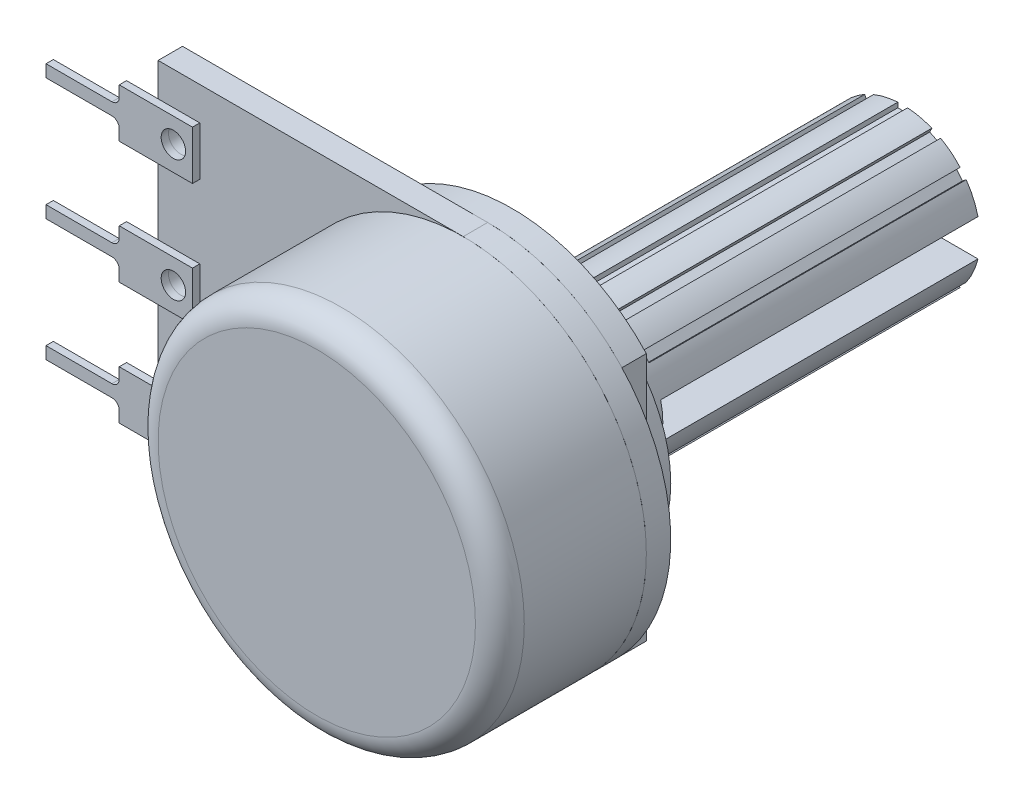
from build123d import *

# Parameters (mm, degrees)
SALIENTE_EXTRUIR1_DEPTH   = 1
CROQUIS4_R                = 7.5
SALIENTE_EXTRUIR2_DEPTH   = 6
SALIENTE_EXTRUIR3_DEPTH   = 1
CROQUIS6_R                = 5.5
SALIENTE_EXTRUIR5_DEPTH   = 1
CROQUIS7_R                = 3.175
SALIENTE_EXTRUIR6_DEPTH   = 15
CORTAR_EXTRUIR1_DEPTH     = 13
SALIENTE_EXTRUIR7_DEPTH   = 0.3
SALIENTE_EXTRUIR7_2_DEPTH = 0.3
SALIENTE_EXTRUIR7_3_DEPTH = 0.3
CROQUIS11_R               = 0.5
CORTAR_EXTRUIR2_DEPTH     = 19.3
REDONDEO1_R               = 1
REDONDEO2_R               = 1


with BuildPart() as part:
    # Croquis3 → Saliente-Extruir1 (new body)
    with BuildSketch(Plane.XY):
        with BuildLine():
            Line((12.5, 0), (0, 0))
            Line((0, 0), (0, 15))
            Line((0, 15), (12.5, 15))
            ThreePointArc((12.5, 15), (20, 7.5), (12.5, 0))
        make_face()
    extrude(amount=SALIENTE_EXTRUIR1_DEPTH)


with BuildPart() as body_2:
    # Croquis4 → Saliente-Extruir2 (new body)
    with BuildSketch(Plane.XY.offset(1)):
        with Locations((12.5, 7.5)):
            Circle(CROQUIS4_R)
    extrude(amount=SALIENTE_EXTRUIR2_DEPTH)

    # Redondeo1
    redondeo1_edges = [body_2.edges().sort_by_distance(p)[0] for p in [
        (5, 7.5, 7),
    ]]
    fillet(redondeo1_edges, radius=REDONDEO1_R)


with BuildPart() as body_3:
    # Croquis5 → Saliente-Extruir3 (new body)
    with BuildSketch(Plane(origin=(0, 0, 0), x_dir=(-1, 0, 0), z_dir=(0, 0, -1))):
        with BuildLine():
            Line((-18, 12.599019514), (-18, 2.400980486))
            ThreePointArc((-18, 2.400980486), (-12.5, 0), (-7, 2.400980486))
            Line((-7, 2.400980486), (-7, 12.599019514))
            ThreePointArc((-7, 12.599019514), (-12.5, 15), (-18, 12.599019514))
        make_face()
    extrude(amount=SALIENTE_EXTRUIR3_DEPTH)

    # Croquis6 → Saliente-Extruir5 (add)
    with BuildSketch(Plane(origin=(0, 0, -1), x_dir=(-1, 0, 0), z_dir=(0, 0, -1))):
        with Locations((-12.5, 7.5)):
            Circle(CROQUIS6_R)
    extrude(amount=SALIENTE_EXTRUIR5_DEPTH)

    # Croquis7 → Saliente-Extruir6 (add)
    with BuildSketch(Plane(origin=(0, 0, -2), x_dir=(-1, 0, 0), z_dir=(0, 0, -1))):
        with Locations((-12.5, 7.5)):
            Circle(CROQUIS7_R)
    extrude(amount=SALIENTE_EXTRUIR6_DEPTH)

    # Croquis9 → Cortar-Extruir1 (cut)
    with BuildSketch(Plane(origin=(0, 0, -17), x_dir=(-1, 0, 0), z_dir=(0, 0, -1))):
        with BuildLine():
            Line((-9.626142568, 8.25), (-15.373857432, 8.25))
            Line((-15.373857432, 8.25), (-15.438767343, 7.965611096))
            Line((-15.438767343, 7.965611096), (-15.633752926, 8.010115283))
            ThreePointArc((-15.633752926, 8.010115283), (-15.675, 7.5), (-15.633752926, 6.989884717))
            Line((-15.633752926, 6.989884717), (-15.438767343, 7.034388904))
            Line((-15.438767343, 7.034388904), (-15.373857432, 6.75))
            Line((-15.373857432, 6.75), (-9.626142568, 6.75))
            Line((-9.626142568, 6.75), (-9.561232657, 7.034388904))
            Line((-9.561232657, 7.034388904), (-9.366247074, 6.989884717))
            ThreePointArc((-9.366247074, 6.989884717), (-9.335328569, 7.244109924), (-9.325, 7.5))
            ThreePointArc((-9.325, 7.5), (-9.335328569, 7.755890076), (-9.366247074, 8.010115283))
            Line((-9.366247074, 8.010115283), (-9.561232657, 7.965611096))
            Line((-9.561232657, 7.965611096), (-9.626142568, 8.25))
        make_face()
        with BuildLine():
            Line((-14.696320882, 9.507317058), (-14.852687178, 9.632015019))
            ThreePointArc((-14.852687178, 9.632015019), (-14.982314957, 9.479580121), (-15.102083099, 9.319282426))
            Line((-15.102083099, 9.319282426), (-14.945716803, 9.194584465))
            Line((-14.945716803, 9.194584465), (-14.696320882, 9.507317058))
        make_face()
        with BuildLine():
            Line((-13.607874508, 10.261478094), (-13.694651256, 10.441671868))
            ThreePointArc((-13.694651256, 10.441671868), (-13.877580872, 10.360576156), (-14.055038803, 10.268118372))
            Line((-14.055038803, 10.268118372), (-13.968262055, 10.087924599))
            Line((-13.968262055, 10.087924599), (-13.607874508, 10.261478094))
        make_face()
        with BuildLine():
            ThreePointArc((-12.3, 10.668694526), (-12.5, 10.675), (-12.7, 10.668694526))
            Line((-12.7, 10.668694526), (-12.7, 10.468694526))
            Line((-12.7, 10.468694526), (-12.3, 10.468694526))
            Line((-12.3, 10.468694526), (-12.3, 10.668694526))
        make_face()
        with BuildLine():
            ThreePointArc((-10.944961197, 10.268118372), (-11.122419128, 10.360576156), (-11.305348744, 10.441671868))
            Line((-11.305348744, 10.441671868), (-11.392125492, 10.261478094))
            Line((-11.392125492, 10.261478094), (-11.031737945, 10.087924599))
            Line((-11.031737945, 10.087924599), (-10.944961197, 10.268118372))
        make_face()
        with BuildLine():
            ThreePointArc((-9.897916901, 9.319282426), (-10.017685043, 9.479580121), (-10.147312822, 9.632015019))
            Line((-10.147312822, 9.632015019), (-10.303679118, 9.507317058))
            Line((-10.303679118, 9.507317058), (-10.054283197, 9.194584465))
            Line((-10.054283197, 9.194584465), (-9.897916901, 9.319282426))
        make_face()
        with BuildLine():
            Line((-14.945716803, 5.805415535), (-15.102083099, 5.680717574))
            ThreePointArc((-15.102083099, 5.680717574), (-14.982314957, 5.520419879), (-14.852687178, 5.367984981))
            Line((-14.852687178, 5.367984981), (-14.696320882, 5.492682942))
            Line((-14.696320882, 5.492682942), (-14.945716803, 5.805415535))
        make_face()
        with BuildLine():
            Line((-13.968262055, 4.912075401), (-14.055038803, 4.731881628))
            ThreePointArc((-14.055038803, 4.731881628), (-13.877580872, 4.639423844), (-13.694651256, 4.558328132))
            Line((-13.694651256, 4.558328132), (-13.607874508, 4.738521906))
            Line((-13.607874508, 4.738521906), (-13.968262055, 4.912075401))
        make_face()
        with BuildLine():
            ThreePointArc((-11.305348744, 4.558328132), (-11.122419128, 4.639423844), (-10.944961197, 4.731881628))
            Line((-10.944961197, 4.731881628), (-11.031737945, 4.912075401))
            Line((-11.031737945, 4.912075401), (-11.392125492, 4.738521906))
            Line((-11.392125492, 4.738521906), (-11.305348744, 4.558328132))
        make_face()
        with BuildLine():
            Line((-12.7, 4.531305474), (-12.7, 4.331305474))
            ThreePointArc((-12.7, 4.331305474), (-12.5, 4.325), (-12.3, 4.331305474))
            Line((-12.3, 4.331305474), (-12.3, 4.531305474))
            Line((-12.3, 4.531305474), (-12.7, 4.531305474))
        make_face()
        with BuildLine():
            ThreePointArc((-10.147312822, 5.367984981), (-10.017685043, 5.520419879), (-9.897916901, 5.680717574))
            Line((-9.897916901, 5.680717574), (-10.054283197, 5.805415535))
            Line((-10.054283197, 5.805415535), (-10.303679118, 5.492682942))
            Line((-10.303679118, 5.492682942), (-10.147312822, 5.367984981))
        make_face()
        with BuildLine():
            Line((-15.438767343, 7.034388904), (-15.633752926, 6.989884717))
            ThreePointArc((-15.633752926, 6.989884717), (-15.611761833, 6.869473797), (-15.585145864, 6.75))
            Line((-15.585145864, 6.75), (-15.373857432, 6.75))
            Line((-15.373857432, 6.75), (-15.438767343, 7.034388904))
        make_face()
        with BuildLine():
            ThreePointArc((-9.414854136, 6.75), (-9.388238167, 6.869473797), (-9.366247074, 6.989884717))
            Line((-9.366247074, 6.989884717), (-9.561232657, 7.034388904))
            Line((-9.561232657, 7.034388904), (-9.626142568, 6.75))
            Line((-9.626142568, 6.75), (-9.414854136, 6.75))
        make_face()
        with BuildLine():
            ThreePointArc((-9.366247074, 8.010115283), (-9.388238167, 8.130526203), (-9.414854136, 8.25))
            Line((-9.414854136, 8.25), (-9.626142568, 8.25))
            Line((-9.626142568, 8.25), (-9.561232657, 7.965611096))
            Line((-9.561232657, 7.965611096), (-9.366247074, 8.010115283))
        make_face()
        with BuildLine():
            Line((-15.373857432, 8.25), (-15.585145864, 8.25))
            ThreePointArc((-15.585145864, 8.25), (-15.611761833, 8.130526203), (-15.633752926, 8.010115283))
            Line((-15.633752926, 8.010115283), (-15.438767343, 7.965611096))
            Line((-15.438767343, 7.965611096), (-15.373857432, 8.25))
        make_face()
    extrude(amount=-CORTAR_EXTRUIR1_DEPTH, mode=Mode.SUBTRACT)

    # Redondeo2
    redondeo2_edges = [body_3.edges().sort_by_distance(p)[0] for p in [
        (15.675, 7.5, -2),
    ]]
    fillet(redondeo2_edges, radius=REDONDEO2_R)


with BuildPart() as body_4:
    # Croquis10 → Saliente-Extruir7 (new body)
    with BuildSketch(Plane.XY.offset(1)):
        with BuildLine():
            Line((1.707822632, 13.636249798), (-1.292177368, 13.636249798))
            Line((-1.292177368, 13.636249798), (-1.292177368, 13.186249798))
            ThreePointArc((-1.292177368, 13.186249798), (-1.380045334, 12.974117764), (-1.592177368, 12.886249798))
            Line((-1.592177368, 12.886249798), (-4.292177368, 12.886249798))
            Line((-4.292177368, 12.886249798), (-4.292177368, 12.386249798))
            Line((-4.292177368, 12.386249798), (-1.592177368, 12.386249798))
            ThreePointArc((-1.592177368, 12.386249798), (-1.380045334, 12.298381833), (-1.292177368, 12.086249798))
            Line((-1.292177368, 12.086249798), (-1.292177368, 11.636249798))
            Line((-1.292177368, 11.636249798), (1.707822632, 11.636249798))
            Line((1.707822632, 11.636249798), (1.707822632, 13.636249798))
        make_face()
    extrude(amount=SALIENTE_EXTRUIR7_DEPTH)


with BuildPart() as body_5:
    # Croquis10 → Saliente-Extruir7 2 (new body)
    with BuildSketch(Plane.XY.offset(1)):
        with BuildLine():
            Line((1.707822632, 6.636249798), (-1.292177368, 6.636249798))
            Line((-1.292177368, 6.636249798), (-1.292177368, 7.086249798))
            ThreePointArc((-1.292177368, 7.086249798), (-1.380045334, 7.298381833), (-1.592177368, 7.386249798))
            Line((-1.592177368, 7.386249798), (-4.292177368, 7.386249798))
            Line((-4.292177368, 7.386249798), (-4.292177368, 7.886249798))
            Line((-4.292177368, 7.886249798), (-1.592177368, 7.886249798))
            ThreePointArc((-1.592177368, 7.886249798), (-1.380045334, 7.974117764), (-1.292177368, 8.186249798))
            Line((-1.292177368, 8.186249798), (-1.292177368, 8.636249798))
            Line((-1.292177368, 8.636249798), (1.707822632, 8.636249798))
            Line((1.707822632, 8.636249798), (1.707822632, 6.636249798))
        make_face()
    extrude(amount=SALIENTE_EXTRUIR7_2_DEPTH)


with BuildPart() as body_6:
    # Croquis10 → Saliente-Extruir7 3 (new body)
    with BuildSketch(Plane.XY.offset(1)):
        with BuildLine():
            Line((1.707822632, 1.636249798), (-1.292177368, 1.636249798))
            Line((-1.292177368, 1.636249798), (-1.292177368, 2.086249798))
            ThreePointArc((-1.292177368, 2.086249798), (-1.380045334, 2.298381833), (-1.592177368, 2.386249798))
            Line((-1.592177368, 2.386249798), (-4.292177368, 2.386249798))
            Line((-4.292177368, 2.386249798), (-4.292177368, 2.886249798))
            Line((-4.292177368, 2.886249798), (-1.592177368, 2.886249798))
            ThreePointArc((-1.592177368, 2.886249798), (-1.380045334, 2.974117764), (-1.292177368, 3.186249798))
            Line((-1.292177368, 3.186249798), (-1.292177368, 3.636249798))
            Line((-1.292177368, 3.636249798), (1.707822632, 3.636249798))
            Line((1.707822632, 3.636249798), (1.707822632, 1.636249798))
        make_face()
    extrude(amount=SALIENTE_EXTRUIR7_3_DEPTH)


with BuildPart() as cortar_extruir2_tool:
    # Croquis11 → Cortar-Extruir2 (new body, through all)
    with BuildSketch(Plane.XY.offset(1.3)):
        with Locations((0.925206345, 12.636249798)):
            Circle(CROQUIS11_R)
        with Locations((0.925206345, 7.636249798)):
            Circle(CROQUIS11_R)
        with Locations((0.925206345, 2.636249798)):
            Circle(CROQUIS11_R)
    extrude(amount=-CORTAR_EXTRUIR2_DEPTH)


with BuildPart() as part_1:
    add(part.part)

    # Cortar-Extruir2: cut by cortar_extruir2_tool
    add(cortar_extruir2_tool.part, mode=Mode.SUBTRACT)


with BuildPart() as body_4_1:
    add(body_4.part)

    # Cortar-Extruir2: cut by cortar_extruir2_tool
    add(cortar_extruir2_tool.part, mode=Mode.SUBTRACT)


with BuildPart() as body_5_1:
    add(body_5.part)

    # Cortar-Extruir2: cut by cortar_extruir2_tool
    add(cortar_extruir2_tool.part, mode=Mode.SUBTRACT)


with BuildPart() as body_6_1:
    add(body_6.part)

    # Cortar-Extruir2: cut by cortar_extruir2_tool
    add(cortar_extruir2_tool.part, mode=Mode.SUBTRACT)


solid = Compound([body_2.part, body_3.part, part_1.part, body_4_1.part, body_5_1.part, body_6_1.part])
